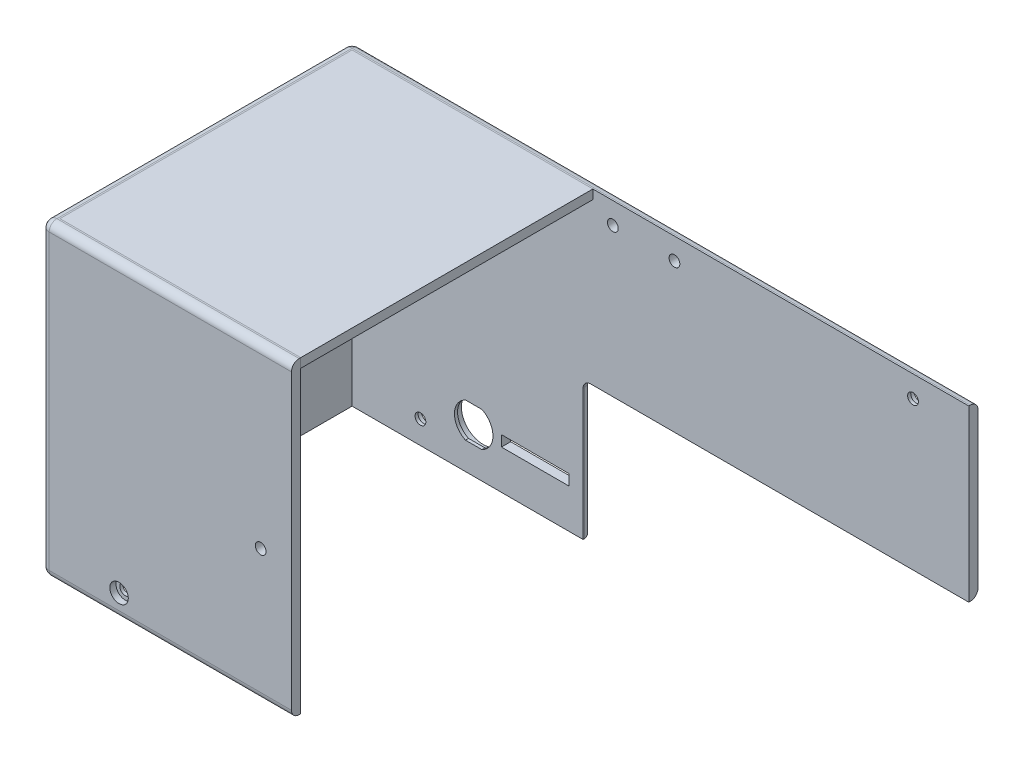
from build123d import *

# Parameters (mm, degrees)
MAIN_BODY_DEPTH                  = 100.2
SKETCH5_R                        = 1.75
BACK_SCREW_HOLES_DEPTH           = 10
SKETCH12_R                       = 3
BACK_SCREW_HEADS_DEPTH           = 2
SKETCH6_W                        = 220
SKETCH6_H                        = 45
PAPER_THROUGH_HOLE_DEPTH         = 10
SKETCH7_R                        = 1.75
FRONT_LEFT_SCREW_HOLE_DEPTH      = 10
SKETCH8_R                        = 3
FRONT_LEFT_SCREW_HEAD_DEPTH      = 2
SKETCH9_W                        = 78.2
SKETCH9_H                        = 94.9
BOSS_EXTRUDE1_DEPTH              = 3
SKETCH10_R                       = 1.75
HINGE_HOLES_DEPTH                = 10
SKETCH11_R                       = 1.75
LATCH_HOLE_DEPTH                 = 10
FILLET3_R                        = 2.5
SKETCH13_R                       = 7
BARRE_JACK_OUTER_CUTOUT_DEPTH    = 2
BARREL_JACK_INNER_CUTOUT_DEPTH   = 1
SKETCH15_W                       = 22
SKETCH15_H                       = 3.5
KEYBOARD_CABLE_PASSTHROUGH_DEPTH = 3


with BuildPart() as part:
    # Sketch1 → Main_Body (new body)
    with BuildSketch(Plane(origin=(0, 0, 0), x_dir=(1, 0, 0), z_dir=(0, 1, 0))):
        Polygon((0, 0), (203.3, 0), (203.3, -3), (3, -3), (3, -97.9), (81.2, -97.9), (81.2, -100.9), (0, -100.9), align=None)
    extrude(amount=MAIN_BODY_DEPTH)

    # Sketch5 → Back_Screw_Holes (cut)
    with BuildSketch(Plane(origin=(0, 0, 0), x_dir=(-1, 0, 0), z_dir=(0, 0, -1))):
        with Locations((-25.2, 7.5)):
            Circle(SKETCH5_R)
        with Locations((-185.2, 7.5)):
            Circle(SKETCH5_R)
        with Locations((-185.2, 93.2)):
            Circle(SKETCH5_R)
    extrude(amount=-BACK_SCREW_HOLES_DEPTH, mode=Mode.SUBTRACT)

    # Sketch12 → Back_Screw_Heads (cut)
    with BuildSketch(Plane(origin=(0, 0, 0), x_dir=(-1, 0, 0), z_dir=(0, 0, -1))):
        with Locations((-25.2, 7.5)):
            Circle(SKETCH12_R)
        with Locations((-185.2, 7.5)):
            Circle(SKETCH12_R)
        with Locations((-185.2, 93.2)):
            Circle(SKETCH12_R)
    extrude(amount=-BACK_SCREW_HEADS_DEPTH, mode=Mode.SUBTRACT)

    # Sketch6 → Paper_Through_Hole (cut)
    with BuildSketch(Plane.XY.offset(3)):
        with Locations((188, 22.5)):
            Rectangle(SKETCH6_W, SKETCH6_H)
    extrude(amount=-PAPER_THROUGH_HOLE_DEPTH, mode=Mode.SUBTRACT)

    # Sketch7 → Front_Left_Screw_Hole (cut)
    with BuildSketch(Plane.XY.offset(100.9)):
        with Locations((25.2, 7.5)):
            Circle(SKETCH7_R)
    extrude(amount=-FRONT_LEFT_SCREW_HOLE_DEPTH, mode=Mode.SUBTRACT)

    # Sketch8 → Front_Left_Screw_Head (cut)
    with BuildSketch(Plane.XY.offset(100.9)):
        with Locations((25.2, 7.5)):
            Circle(SKETCH8_R)
    extrude(amount=-FRONT_LEFT_SCREW_HEAD_DEPTH, mode=Mode.SUBTRACT)

    # Sketch10 → Hinge_Holes (cut)
    with BuildSketch(Plane(origin=(0, 0, 0), x_dir=(-1, 0, 0), z_dir=(0, 0, -1))):
        with Locations((-107.7, 93.2)):
            Circle(SKETCH10_R)
        with Locations((-87.7, 93.2)):
            Circle(SKETCH10_R)
    extrude(amount=-HINGE_HOLES_DEPTH, mode=Mode.SUBTRACT)

    # Sketch11 → Latch_Hole (cut)
    with BuildSketch(Plane.XY.offset(100.9)):
        with Locations((71.2, 43)):
            Circle(SKETCH11_R)
    extrude(amount=-LATCH_HOLE_DEPTH, mode=Mode.SUBTRACT)

    # Fillet3
    fillet3_edges = [part.edges().sort_by_distance(p)[0] for p in [
        (40.6, 0, 100.9),
        (0, 0, 50.45),
        (0, 50.1, 0),
        (0, 50.1, 100.9),
        (101.65, 100.2, 0),
        (0, 100.2, 50.45),
        (39, 0, 0),
        (140.65, 45, 0),
        (78, 45, 1.5),
        (78, 22.5, 0),
        (40.6, 100.2, 100.9),
    ]]
    fillet(fillet3_edges, radius=FILLET3_R)

    # Sketch13 → Barre_Jack_Outer_Cutout (cut)
    with BuildSketch(Plane(origin=(0, 0, 0), x_dir=(-1, 0, 0), z_dir=(0, 0, -1))):
        with Locations((-42.5, 14.5)):
            Circle(SKETCH13_R)
    extrude(amount=-BARRE_JACK_OUTER_CUTOUT_DEPTH, mode=Mode.SUBTRACT)

    # Sketch14 → Barrel_Jack_Inner_Cutout (cut)
    with BuildSketch(Plane(origin=(0, 0, 2), x_dir=(-1, 0, 0), z_dir=(0, 0, -1))):
        with BuildLine():
            Line((-45.172077843, 20.15), (-39.827922157, 20.15))
            ThreePointArc((-39.827922157, 20.15), (-36.25, 14.5), (-39.827922157, 8.85))
            Line((-39.827922157, 8.85), (-45.172077843, 8.85))
            ThreePointArc((-45.172077843, 8.85), (-48.75, 14.5), (-45.172077843, 20.15))
        make_face()
    extrude(amount=-BARREL_JACK_INNER_CUTOUT_DEPTH, mode=Mode.SUBTRACT)

    # Sketch15 → Keyboard_Cable_Passthrough (cut)
    with BuildSketch(Plane(origin=(0, 0, 0), x_dir=(-1, 0, 0), z_dir=(0, 0, -1))):
        with Locations((-62.5, 14.5)):
            Rectangle(SKETCH15_W, SKETCH15_H)
    extrude(amount=-KEYBOARD_CABLE_PASSTHROUGH_DEPTH, mode=Mode.SUBTRACT)


with BuildPart() as body_2:
    # Sketch9 → Boss-Extrude1 (new body)
    with BuildSketch(Plane(origin=(0, 100.2, 0), x_dir=(1, 0, 0), z_dir=(0, 1, 0))):
        with Locations((42.1, -50.45)):
            Rectangle(SKETCH9_W, SKETCH9_H)
    extrude(amount=-BOSS_EXTRUDE1_DEPTH)


solid = Compound([part.part, body_2.part])
